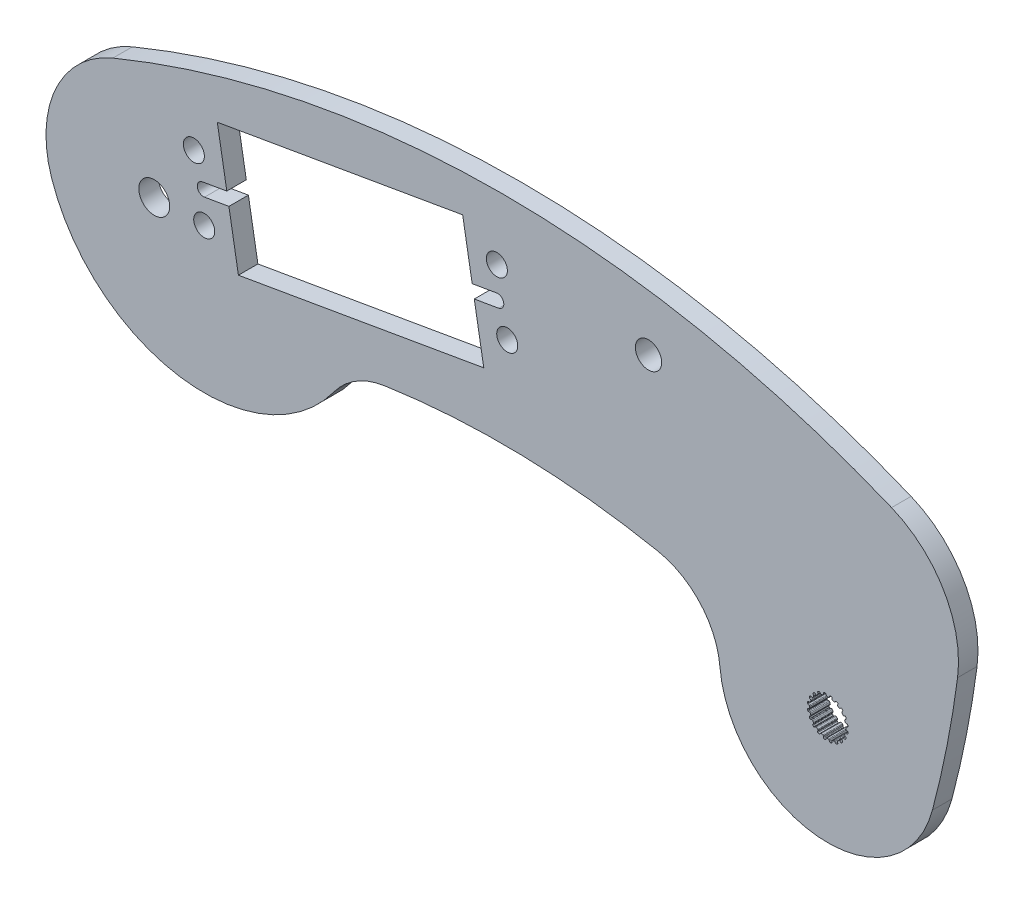
from build123d import *

# Parameters (mm, degrees)
BOSS_EXTRUDE1_DEPTH = 3.2004
BOSS_EXTRUDE2_DEPTH = 3.2004
SKETCH2_R           = 1.7272
SKETCH2_R_2         = 2.54
CUT_EXTRUDE1_DEPTH  = 3.2004
CUT_EXTRUDE3_DEPTH  = 3.2004
CUT_EXTRUDE4_DEPTH  = 3.2004
FILLET1_R           = 12.7
BOSS_EXTRUDE3_DEPTH = 3.2004
SKETCH10_R          = 2.159
CUT_EXTRUDE5_DEPTH  = 3.2004


with BuildPart() as part:
    # Sketch1 → Boss-Extrude1 (new body)
    with BuildSketch(Plane.XY):
        with BuildLine():
            ThreePointArc((-6.790095085, 16.435726481), (57.15, 29.123460788), (121.090095085, 16.435726481))
            ThreePointArc((121.090095085, 16.435726481), (130.735726481, -6.790095085), (107.509904915, -16.435726481))
            ThreePointArc((107.509904915, -16.435726481), (57.15, -6.442730812), (6.790095085, -16.435726481))
            ThreePointArc((6.790095085, -16.435726481), (-16.435726481, -6.790095085), (-6.790095085, 16.435726481))
        make_face()
    extrude(amount=BOSS_EXTRUDE1_DEPTH)

    # Sketch3 → Boss-Extrude2 (add)
    with BuildSketch(Plane.XY.offset(3.2004)):
        with BuildLine():
            ThreePointArc((96.670173634, 2.329746452), (116.629746452, 17.629826366), (131.929826366, -2.329746452))
            ThreePointArc((131.929826366, -2.329746452), (130.197200475, -12.850112517), (127.798590387, -23.238893209))
            ThreePointArc((127.798590387, -23.238893209), (106.05729345, -35.879818808), (93.416367852, -14.138521872))
            ThreePointArc((93.416367852, -14.138521872), (95.305538892, -5.956206736), (96.670173634, 2.329746452))
        make_face()
    extrude(amount=-BOSS_EXTRUDE2_DEPTH)

    # Sketch2 → Cut-Extrude1 (cut)
    with BuildSketch(Plane.XY.offset(3.2004)):
        with Locations((57.969230315, 8.733730887)):
            Circle(SKETCH2_R)
        with Locations((6.503666478, 9.977008918)):
            Circle(SKETCH2_R)
        with Locations((8.208675832, 0.123433708)):
            Circle(SKETCH2_R)
        with Locations((56.264220961, 18.587306097)):
            Circle(SKETCH2_R)
        Circle(SKETCH2_R_2)
        Polygon((10.356553805, 15.880369647), (50.651764004, 22.852834853), (54.116342988, 2.830370158), (13.821132789, -4.142095048), align=None)
    extrude(amount=-CUT_EXTRUDE1_DEPTH, mode=Mode.SUBTRACT)

    # Sketch7 → Cut-Extrude3 (cut)
    with BuildSketch(Plane.XY.offset(3.2004)):
        with BuildLine():
            Line((110.500529874, -15.718832607), (110.714428364, -15.718832607))
            ThreePointArc((110.714428364, -15.718832607), (110.803822332, -15.701783365), (110.861218357, -15.631160037))
            Line((110.861218357, -15.631160037), (110.923367267, -15.4511806))
            ThreePointArc((110.923367267, -15.4511806), (110.966511275, -15.390384629), (111.035624019, -15.362438535))
            Line((111.035624019, -15.362438535), (111.227506707, -15.394952841))
            ThreePointArc((111.227506707, -15.394952841), (111.297100261, -15.440681781), (111.325751331, -15.51887075))
            Line((111.325751331, -15.51887075), (111.331868286, -15.709180149))
            ThreePointArc((111.331868286, -15.709180149), (111.358413881, -15.784641441), (111.423506169, -15.831139498))
            Line((111.423506169, -15.831139498), (111.626935721, -15.897237766))
            ThreePointArc((111.626935721, -15.897237766), (111.717222943, -15.908647229), (111.793633615, -15.8592168))
            Line((111.793633615, -15.8592168), (111.908357445, -15.707251253))
            ThreePointArc((111.908357445, -15.707251253), (111.968176823, -15.662763081), (112.042542767, -15.657541778))
            Line((112.042542767, -15.657541778), (112.214986574, -15.747759732))
            ThreePointArc((112.214986574, -15.747759732), (112.267042958, -15.812756129), (112.270130024, -15.895971925))
            Line((112.270130024, -15.895971925), (112.217138755, -16.078857163))
            ThreePointArc((112.217138755, -16.078857163), (112.219066295, -16.158828156), (112.26660405, -16.223165059))
            Line((112.26660405, -16.223165059), (112.439651563, -16.348891437))
            ThreePointArc((112.439651563, -16.348891437), (112.521994096, -16.387642766), (112.609939806, -16.364243831))
            Line((112.609939806, -16.364243831), (112.766008588, -16.25516762))
            ThreePointArc((112.766008588, -16.25516762), (112.8366478, -16.231342059), (112.908987486, -16.249356646))
            Line((112.908987486, -16.249356646), (113.045112412, -16.388447085))
            ThreePointArc((113.045112412, -16.388447085), (113.074535984, -16.46634864), (113.051756863, -16.546445521))
            Line((113.051756863, -16.546445521), (112.944844525, -16.704004515))
            ThreePointArc((112.944844525, -16.704004515), (112.921965328, -16.780657092), (112.947295223, -16.856535097))
            Line((112.947295223, -16.856535097), (113.073021601, -17.02958261))
            ThreePointArc((113.073021601, -17.02958261), (113.139359184, -17.091882556), (113.230231193, -17.096805566))
            Line((113.230231193, -17.096805566), (113.412367828, -17.041295831))
            ThreePointArc((113.412367828, -17.041295831), (113.486912214, -17.040465092), (113.55014453, -17.079952174))
            Line((113.55014453, -17.079952174), (113.636625719, -17.254299959))
            ThreePointArc((113.636625719, -17.254299959), (113.640536294, -17.337481124), (113.594120765, -17.406618649))
            Line((113.594120765, -17.406618649), (113.443752683, -17.523428428))
            ThreePointArc((113.443752683, -17.523428428), (113.398306325, -17.5892593), (113.398948893, -17.669250939))
            Line((113.398948893, -17.669250939), (113.465047162, -17.872680491))
            ThreePointArc((113.465047162, -17.872680491), (113.50888621, -17.952430701), (113.593789333, -17.985193757))
            Line((113.593789333, -17.985193757), (113.784165019, -17.988684177))
            ThreePointArc((113.784165019, -17.988684177), (113.855317655, -18.01092958), (113.903252982, -18.068023887))
            Line((113.903252982, -18.068023887), (113.931625051, -18.260562641))
            ThreePointArc((113.931625051, -18.260562641), (113.909639836, -18.340881064), (113.844131375, -18.392291571))
            Line((113.844131375, -18.392291571), (113.665026623, -18.456917979))
            ThreePointArc((113.665026623, -18.456917979), (113.60146171, -18.505483162), (113.577354053, -18.581758296))
            Line((113.577354053, -18.581758296), (113.577354053, -18.795656786))
            ThreePointArc((113.577354053, -18.795656786), (113.594403295, -18.885050754), (113.665026623, -18.942446779))
            Line((113.665026623, -18.942446779), (113.84500606, -19.004595688))
            ThreePointArc((113.84500606, -19.004595688), (113.90580203, -19.047739697), (113.933748125, -19.116852441))
            Line((113.933748125, -19.116852441), (113.901233819, -19.308735128))
            ThreePointArc((113.901233819, -19.308735128), (113.855504879, -19.378328683), (113.77731591, -19.406979753))
            Line((113.77731591, -19.406979753), (113.58700651, -19.413096707))
            ThreePointArc((113.58700651, -19.413096707), (113.511545219, -19.439642303), (113.465047162, -19.50473459))
            Line((113.465047162, -19.50473459), (113.398948893, -19.708164143))
            ThreePointArc((113.398948893, -19.708164143), (113.387539431, -19.798451364), (113.43696986, -19.874862037))
            Line((113.43696986, -19.874862037), (113.588935407, -19.989585866))
            ThreePointArc((113.588935407, -19.989585866), (113.633423579, -20.049405245), (113.638644882, -20.123771188))
            Line((113.638644882, -20.123771188), (113.548426928, -20.296214996))
            ThreePointArc((113.548426928, -20.296214996), (113.483430531, -20.34827138), (113.400214734, -20.351358446))
            Line((113.400214734, -20.351358446), (113.217329497, -20.298367177))
            ThreePointArc((113.217329497, -20.298367177), (113.137358504, -20.300294717), (113.073021601, -20.347832471))
            Line((113.073021601, -20.347832471), (112.947295223, -20.520879985))
            ThreePointArc((112.947295223, -20.520879985), (112.908543894, -20.603222517), (112.931942829, -20.691168228))
            Line((112.931942829, -20.691168228), (113.04101904, -20.84723701))
            ThreePointArc((113.04101904, -20.84723701), (113.064844601, -20.917876221), (113.046830014, -20.990215907))
            Line((113.046830014, -20.990215907), (112.907739575, -21.126340834))
            ThreePointArc((112.907739575, -21.126340834), (112.82983802, -21.155764405), (112.749741139, -21.132985285))
            Line((112.749741139, -21.132985285), (112.592182145, -21.026072946))
            ThreePointArc((112.592182145, -21.026072946), (112.515529568, -21.00319375), (112.439651563, -21.028523645))
            Line((112.439651563, -21.028523645), (112.26660405, -21.154250022))
            ThreePointArc((112.26660405, -21.154250022), (112.204304104, -21.220587605), (112.199381094, -21.311459615))
            Line((112.199381094, -21.311459615), (112.254890829, -21.49359625))
            ThreePointArc((112.254890829, -21.49359625), (112.255721568, -21.568140636), (112.216234486, -21.631372952))
            Line((112.216234486, -21.631372952), (112.041886701, -21.71785414))
            ThreePointArc((112.041886701, -21.71785414), (111.958705536, -21.721764716), (111.889568011, -21.675349187))
            Line((111.889568011, -21.675349187), (111.772758232, -21.524981105))
            ThreePointArc((111.772758232, -21.524981105), (111.70692736, -21.479534747), (111.626935721, -21.480177315))
            Line((111.626935721, -21.480177315), (111.423506169, -21.546275584))
            ThreePointArc((111.423506169, -21.546275584), (111.343755958, -21.590114632), (111.310992903, -21.675017755))
            Line((111.310992903, -21.675017755), (111.307502483, -21.86539344))
            ThreePointArc((111.307502483, -21.86539344), (111.28525708, -21.936546076), (111.228162773, -21.984481404))
            Line((111.228162773, -21.984481404), (111.035624019, -22.012853473))
            ThreePointArc((111.035624019, -22.012853473), (110.955305596, -21.990868258), (110.903895089, -21.925359796))
            Line((110.903895089, -21.925359796), (110.839268681, -21.746255045))
            ThreePointArc((110.839268681, -21.746255045), (110.790703498, -21.682690132), (110.714428364, -21.658582475))
            Line((110.714428364, -21.658582475), (110.500529874, -21.658582475))
            ThreePointArc((110.500529874, -21.658582475), (110.411135906, -21.675631717), (110.353739881, -21.746255045))
            Line((110.353739881, -21.746255045), (110.291590972, -21.926234482))
            ThreePointArc((110.291590972, -21.926234482), (110.248446963, -21.987030452), (110.179334219, -22.014976546))
            Line((110.179334219, -22.014976546), (109.987451531, -21.982462241))
            ThreePointArc((109.987451531, -21.982462241), (109.917857977, -21.936733301), (109.889206907, -21.858544331))
            Line((109.889206907, -21.858544331), (109.883089953, -21.668234932))
            ThreePointArc((109.883089953, -21.668234932), (109.856544357, -21.59277364), (109.79145207, -21.546275584))
            Line((109.79145207, -21.546275584), (109.588022517, -21.480177315))
            ThreePointArc((109.588022517, -21.480177315), (109.497735296, -21.468767853), (109.421324623, -21.518198282))
            Line((109.421324623, -21.518198282), (109.306600794, -21.670163829))
            ThreePointArc((109.306600794, -21.670163829), (109.246781415, -21.714652001), (109.172415471, -21.719873303))
            Line((109.172415471, -21.719873303), (108.999971664, -21.62965535))
            ThreePointArc((108.999971664, -21.62965535), (108.94791528, -21.564658952), (108.944828214, -21.481443156))
            Line((108.944828214, -21.481443156), (108.997819483, -21.298557919))
            ThreePointArc((108.997819483, -21.298557919), (108.995891943, -21.218586925), (108.948354188, -21.154250022))
            Line((108.948354188, -21.154250022), (108.775306675, -21.028523645))
            ThreePointArc((108.775306675, -21.028523645), (108.692964143, -20.989772315), (108.605018432, -21.01317125))
            Line((108.605018432, -21.01317125), (108.44894965, -21.122247461))
            ThreePointArc((108.44894965, -21.122247461), (108.378310439, -21.146073022), (108.305970752, -21.128058436))
            Line((108.305970752, -21.128058436), (108.169845826, -20.988967996))
            ThreePointArc((108.169845826, -20.988967996), (108.140422255, -20.911066442), (108.163201375, -20.830969561))
            Line((108.163201375, -20.830969561), (108.270113713, -20.673410567))
            ThreePointArc((108.270113713, -20.673410567), (108.29299291, -20.59675799), (108.267663015, -20.520879985))
            Line((108.267663015, -20.520879985), (108.141936637, -20.347832471))
            ThreePointArc((108.141936637, -20.347832471), (108.075599055, -20.285532525), (107.984727045, -20.280609516))
            Line((107.984727045, -20.280609516), (107.80259041, -20.336119251))
            ThreePointArc((107.80259041, -20.336119251), (107.728046024, -20.336949989), (107.664813708, -20.297462907))
            Line((107.664813708, -20.297462907), (107.578332519, -20.123115123))
            ThreePointArc((107.578332519, -20.123115123), (107.574421944, -20.039933958), (107.620837473, -19.970796432))
            Line((107.620837473, -19.970796432), (107.771205555, -19.853986654))
            ThreePointArc((107.771205555, -19.853986654), (107.816651913, -19.788155782), (107.816009345, -19.708164143))
            Line((107.816009345, -19.708164143), (107.749911076, -19.50473459))
            ThreePointArc((107.749911076, -19.50473459), (107.706072028, -19.42498438), (107.621168905, -19.392221324))
            Line((107.621168905, -19.392221324), (107.430793219, -19.388730904))
            ThreePointArc((107.430793219, -19.388730904), (107.359640584, -19.366485502), (107.311705256, -19.309391194))
            Line((107.311705256, -19.309391194), (107.283333187, -19.116852441))
            ThreePointArc((107.283333187, -19.116852441), (107.305318402, -19.036534018), (107.370826864, -18.985123511))
            Line((107.370826864, -18.985123511), (107.549931615, -18.920497103))
            ThreePointArc((107.549931615, -18.920497103), (107.613496528, -18.87193192), (107.637604185, -18.795656786))
            Line((107.637604185, -18.795656786), (107.637604185, -18.581758296))
            ThreePointArc((107.637604185, -18.581758296), (107.620554943, -18.492364328), (107.549931615, -18.434968302))
            Line((107.549931615, -18.434968302), (107.369952178, -18.372819393))
            ThreePointArc((107.369952178, -18.372819393), (107.309156208, -18.329675384), (107.281210114, -18.260562641))
            Line((107.281210114, -18.260562641), (107.313724419, -18.068679953))
            ThreePointArc((107.313724419, -18.068679953), (107.359453359, -17.999086399), (107.437642328, -17.970435329))
            Line((107.437642328, -17.970435329), (107.627951728, -17.964318374))
            ThreePointArc((107.627951728, -17.964318374), (107.70341302, -17.937772779), (107.749911076, -17.872680491))
            Line((107.749911076, -17.872680491), (107.816009345, -17.669250939))
            ThreePointArc((107.816009345, -17.669250939), (107.827418807, -17.578963717), (107.777988378, -17.502553045))
            Line((107.777988378, -17.502553045), (107.626022831, -17.387829215))
            ThreePointArc((107.626022831, -17.387829215), (107.581534659, -17.328009836), (107.576313357, -17.253643893))
            Line((107.576313357, -17.253643893), (107.66653131, -17.081200086))
            ThreePointArc((107.66653131, -17.081200086), (107.731527707, -17.029143702), (107.814743504, -17.026056635))
            Line((107.814743504, -17.026056635), (107.997628741, -17.079047904))
            ThreePointArc((107.997628741, -17.079047904), (108.077599734, -17.077120365), (108.141936637, -17.02958261))
            Line((108.141936637, -17.02958261), (108.267663015, -16.856535097))
            ThreePointArc((108.267663015, -16.856535097), (108.306414345, -16.774192564), (108.28301541, -16.686246854))
            Line((108.28301541, -16.686246854), (108.173939199, -16.530178071))
            ThreePointArc((108.173939199, -16.530178071), (108.150113637, -16.45953886), (108.168128224, -16.387199174))
            Line((108.168128224, -16.387199174), (108.307218664, -16.251074248))
            ThreePointArc((108.307218664, -16.251074248), (108.385120218, -16.221650676), (108.465217099, -16.244429797))
            Line((108.465217099, -16.244429797), (108.622776093, -16.351342135))
            ThreePointArc((108.622776093, -16.351342135), (108.69942867, -16.374221332), (108.775306675, -16.348891437))
            Line((108.775306675, -16.348891437), (108.948354188, -16.223165059))
            ThreePointArc((108.948354188, -16.223165059), (109.010654135, -16.156827476), (109.015577144, -16.065955467))
            Line((109.015577144, -16.065955467), (108.960067409, -15.883818831))
            ThreePointArc((108.960067409, -15.883818831), (108.95923667, -15.809274446), (108.998723753, -15.746042129))
            Line((108.998723753, -15.746042129), (109.173071537, -15.659560941))
            ThreePointArc((109.173071537, -15.659560941), (109.256252702, -15.655650366), (109.325390227, -15.702065894))
            Line((109.325390227, -15.702065894), (109.442200006, -15.852433977))
            ThreePointArc((109.442200006, -15.852433977), (109.508030878, -15.897880335), (109.588022517, -15.897237766))
            Line((109.588022517, -15.897237766), (109.79145207, -15.831139498))
            ThreePointArc((109.79145207, -15.831139498), (109.87120228, -15.78730045), (109.903965335, -15.702397326))
            Line((109.903965335, -15.702397326), (109.907455756, -15.512021641))
            ThreePointArc((109.907455756, -15.512021641), (109.929701158, -15.440869005), (109.986795466, -15.392933678))
            Line((109.986795466, -15.392933678), (110.179334219, -15.364561609))
            ThreePointArc((110.179334219, -15.364561609), (110.259652642, -15.386546824), (110.311063149, -15.452055285))
            Line((110.311063149, -15.452055285), (110.375689557, -15.631160037))
            ThreePointArc((110.375689557, -15.631160037), (110.42425474, -15.69472495), (110.500529874, -15.718832607))
        make_face()
    extrude(amount=-CUT_EXTRUDE3_DEPTH, mode=Mode.SUBTRACT)

    # Sketch8 → Cut-Extrude4 (cut)
    with BuildSketch(Plane.XY.offset(3.2004)):
        with BuildLine():
            Line((7.911121409, 6.177344738), (11.915614348, 6.870260535))
            Line((11.915614348, 6.870260535), (12.262072246, 4.868014065))
            Line((12.262072246, 4.868014065), (8.257579307, 4.175098268))
            ThreePointArc((8.257579307, 4.175098268), (7.083227123, 5.002992554), (7.911121409, 6.177344738))
        make_face()
        with BuildLine():
            Line((52.210824547, 13.84272574), (56.215317486, 14.535641537))
            ThreePointArc((56.215317486, 14.535641537), (57.38966967, 13.707747251), (56.561775384, 12.533395067))
            Line((56.561775384, 12.533395067), (52.557282445, 11.84047927))
            Line((52.557282445, 11.84047927), (52.210824547, 13.84272574))
        make_face()
    extrude(amount=-CUT_EXTRUDE4_DEPTH, mode=Mode.SUBTRACT)

    # Fillet1
    fillet1_edges = [part.edges().sort_by_distance(p)[0] for p in [
        (94.035611584, -11.705568295, 1.6002),
    ]]
    fillet(fillet1_edges, radius=FILLET1_R)

    # Sketch9 → Boss-Extrude3 (add)
    with BuildSketch(Plane(origin=(0, 0, 0), x_dir=(-1, 0, 0), z_dir=(0, 0, -1))):
        with BuildLine():
            Line((-37.808873496, -7.868571512), (16.868358701, -5.630006302))
            ThreePointArc((16.868358701, -5.630006302), (-4.132337334, -23.377701605), (-29.538208861, -12.863348817))
            ThreePointArc((-29.538208861, -12.863348817), (-33.172340063, -9.536040013), (-37.808873496, -7.868571512))
        make_face()
    extrude(amount=-BOSS_EXTRUDE3_DEPTH)

    # Sketch10 → Cut-Extrude5 (cut)
    with BuildSketch(Plane(origin=(0, 0, 0), x_dir=(-1, 0, 0), z_dir=(0, 0, -1))):
        with Locations((-81.171495518, 18.191790938)):
            Circle(SKETCH10_R)
    extrude(amount=-CUT_EXTRUDE5_DEPTH, mode=Mode.SUBTRACT)


solid = part.part
